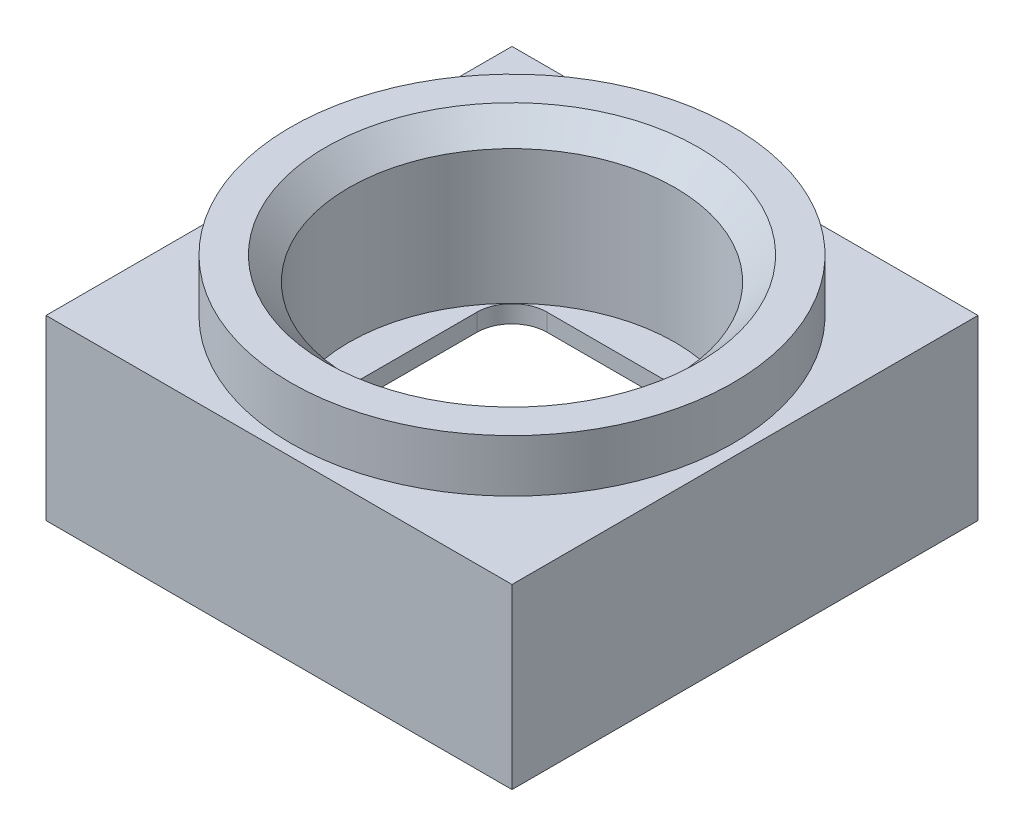
from build123d import *

# Parameters (mm, degrees)
SKIZZE2_W                       = 8
SKIZZE2_H                       = 8
SKIZZE2_W_2                     = 7.4
SKIZZE2_H_2                     = 7.4
AUFSATZ_LINEAR_AUSTRAGEN1_DEPTH = 0.6
SKIZZE5_W                       = 8
SKIZZE5_H                       = 8
AUFSATZ_LINEAR_AUSTRAGEN3_DEPTH = 0.35
SKIZZE4_W                       = 8
SKIZZE4_H                       = 8
AUFSATZ_LINEAR_AUSTRAGEN2_DEPTH = 0.3
SKIZZE7_W                       = 8
SKIZZE7_H                       = 8
SKIZZE7_R                       = 2.8
AUFSATZ_LINEAR_AUSTRAGEN4_DEPTH = 1.8
SKIZZE8_R                       = 3.8
SKIZZE8_R_2                     = 2.8
AUFSATZ_LINEAR_AUSTRAGEN5_DEPTH = 0.9
FASE1_SIZE                      = 0.4


with BuildPart() as part:
    # Skizze2 → Aufsatz-Linear austragen1 (new body)
    with BuildSketch(Plane(origin=(0, 0, 0), x_dir=(1, 0, 0), z_dir=(0, 1, 0))):
        Rectangle(SKIZZE2_W, SKIZZE2_H)
        Rectangle(SKIZZE2_W_2, SKIZZE2_H_2, mode=Mode.SUBTRACT)
    extrude(amount=AUFSATZ_LINEAR_AUSTRAGEN1_DEPTH)

    # Skizze5 → Aufsatz-Linear austragen3 (add)
    with BuildSketch(Plane(origin=(0, 0.6, 0), x_dir=(1, 0, 0), z_dir=(0, 1, 0))):
        Rectangle(SKIZZE5_W, SKIZZE5_H)
        with BuildLine():
            Line((-2.764589803, 3.2), (2.764589803, 3.2))
            ThreePointArc((2.764589803, 3.2), (3.347487373, 3.347487373), (3.2, 2.764589803))
            Line((3.2, 2.764589803), (3.2, -2.764589803))
            ThreePointArc((3.2, -2.764589803), (3.347487373, -3.347487373), (2.764589803, -3.2))
            Line((2.764589803, -3.2), (-2.764589803, -3.2))
            ThreePointArc((-2.764589803, -3.2), (-3.347487373, -3.347487373), (-3.2, -2.764589803))
            Line((-3.2, -2.764589803), (-3.2, 2.764589803))
            ThreePointArc((-3.2, 2.764589803), (-3.347487373, 3.347487373), (-2.764589803, 3.2))
        make_face(mode=Mode.SUBTRACT)
    extrude(amount=AUFSATZ_LINEAR_AUSTRAGEN3_DEPTH)

    # Skizze4 → Aufsatz-Linear austragen2 (add)
    with BuildSketch(Plane(origin=(0, 0.95, 0), x_dir=(1, 0, 0), z_dir=(0, 1, 0))):
        Rectangle(SKIZZE4_W, SKIZZE4_H)
        with BuildLine():
            Line((-1.55, 2.15), (1.55, 2.15))
            ThreePointArc((1.55, 2.15), (1.974264069, 1.974264069), (2.15, 1.55))
            Line((2.15, 1.55), (2.15, -1.55))
            ThreePointArc((2.15, -1.55), (1.974264069, -1.974264069), (1.55, -2.15))
            Line((1.55, -2.15), (-1.55, -2.15))
            ThreePointArc((-1.55, -2.15), (-1.974264069, -1.974264069), (-2.15, -1.55))
            Line((-2.15, -1.55), (-2.15, 1.55))
            ThreePointArc((-2.15, 1.55), (-1.974264069, 1.974264069), (-1.55, 2.15))
        make_face(mode=Mode.SUBTRACT)
    extrude(amount=AUFSATZ_LINEAR_AUSTRAGEN2_DEPTH)

    # Skizze7 → Aufsatz-Linear austragen4 (add)
    with BuildSketch(Plane(origin=(0, 1.25, 0), x_dir=(1, 0, 0), z_dir=(0, 1, 0))):
        Rectangle(SKIZZE7_W, SKIZZE7_H)
        Circle(SKIZZE7_R, mode=Mode.SUBTRACT)
    extrude(amount=AUFSATZ_LINEAR_AUSTRAGEN4_DEPTH)

    # Skizze8 → Aufsatz-Linear austragen5 (add)
    with BuildSketch(Plane(origin=(0, 3.05, 0), x_dir=(1, 0, 0), z_dir=(0, 1, 0))):
        Circle(SKIZZE8_R)
        Circle(SKIZZE8_R_2, mode=Mode.SUBTRACT)
    extrude(amount=AUFSATZ_LINEAR_AUSTRAGEN5_DEPTH)

    # Fase1
    fase1_edges = [part.edges().sort_by_distance(p)[0] for p in [
        (-2.8, 3.95, 0),
    ]]
    chamfer(fase1_edges, length=FASE1_SIZE)


solid = part.part
